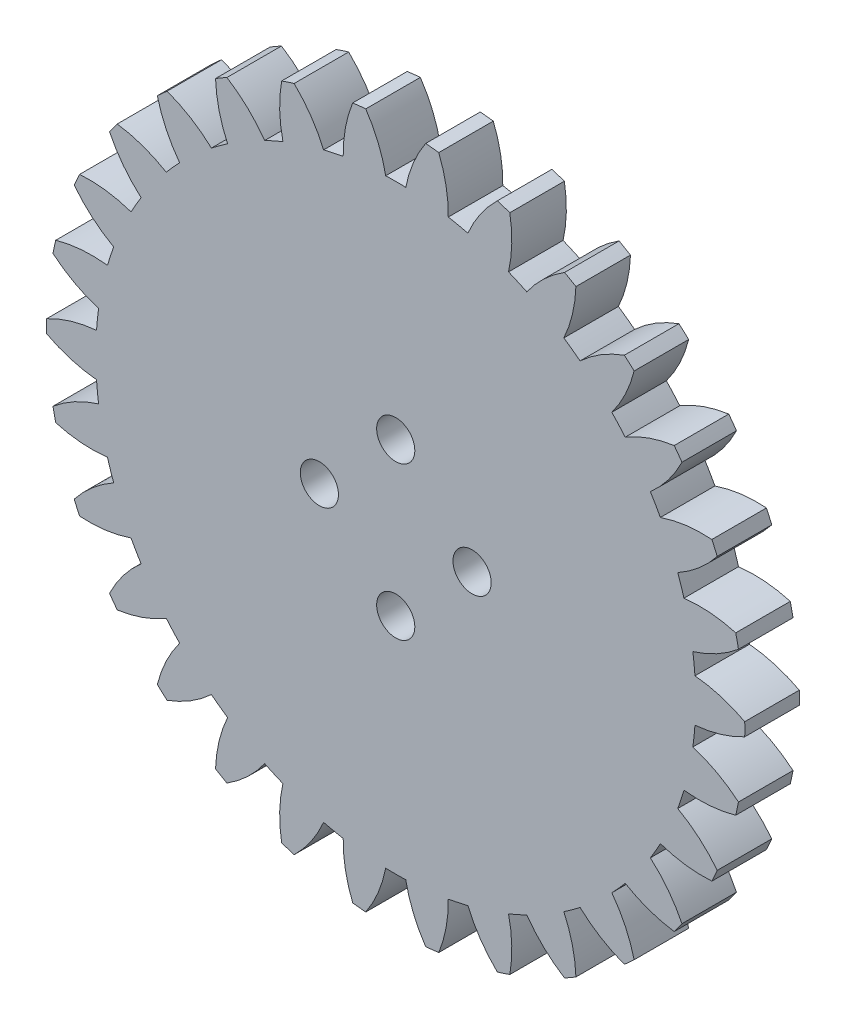
from build123d import *

# Parameters (mm, degrees)
EXTRUDE_1_DEPTH     = 5
SKETCH_2_R          = 1.75
CUT_EXTRUDE_1_DEPTH = 10


with BuildPart() as part:
    # 草图1 → 凸台-拉伸1 (new body)
    with BuildSketch(Plane.XY):
        with BuildLine():
            ThreePointArc((-31.994334603, -0.602124009), (-29.77973059, -1.509475958), (-27.429110937, -1.959304527))
            ThreePointArc((-27.429110937, -1.959304527), (-27.348357601, -2.874428211), (-27.23708137, -3.786343811))
            ThreePointArc((-27.23708137, -3.786343811), (-29.442809726, -4.715063852), (-31.42037025, -6.063030049))
            ThreePointArc((-31.42037025, -6.063030049), (-31.300723223, -6.653174106), (-31.169993008, -7.240962359))
            ThreePointArc((-31.169993008, -7.240962359), (-28.815134328, -7.668044426), (-26.422356736, -7.619321854))
            ThreePointArc((-26.422356736, -7.619321854), (-26.153103142, -8.497658328), (-25.854660649, -9.366510754))
            ThreePointArc((-25.854660649, -9.366510754), (-27.819096794, -10.733532747), (-29.473184945, -12.4632006))
            ThreePointArc((-29.473184945, -12.4632006), (-29.233454645, -13.015572578), (-28.983373149, -13.563335907))
            ThreePointArc((-28.983373149, -13.563335907), (-26.591178426, -13.491482557), (-24.260818757, -12.946338255))
            ThreePointArc((-24.260818757, -12.946338255), (-23.814832579, -13.7495), (-23.342267194, -14.537316233))
            ThreePointArc((-23.342267194, -14.537316233), (-24.979555842, -16.282894755), (-26.23788003, -18.31866948))
            ThreePointArc((-26.23788003, -18.31866948), (-25.88854382, -18.809128073), (-25.530040805, -19.292926592))
            ThreePointArc((-25.530040805, -19.292926592), (-23.205060428, -18.725278161), (-21.038966583, -17.707537551))
            ThreePointArc((-21.038966583, -17.707537551), (-20.435739556, -18.400422544), (-19.809704653, -19.072771234))
            ThreePointArc((-19.809704653, -19.072771234), (-21.048288434, -21.120616129), (-21.855853854, -23.373524601))
            ThreePointArc((-21.855853854, -23.373524601), (-21.412179403, -23.780634415), (-20.960923171, -24.179323808))
            ThreePointArc((-20.960923171, -24.179323808), (-18.804769939, -23.140689255), (-16.897610612, -21.694832486))
            ThreePointArc((-16.897610612, -21.694832486), (-16.163506653, -22.247158328), (-15.411362962, -22.774654611))
            ThreePointArc((-15.411362962, -22.774654611), (-16.197109821, -25.035265229), (-16.518621989, -27.406844539))
            ThreePointArc((-16.518621989, -27.406844539), (-16, -27.712812921), (-15.475712613, -28.008968548))
            ThreePointArc((-15.475712613, -28.008968548), (-13.582620769, -26.544741188), (-12.017747974, -24.733959138))
            ThreePointArc((-12.017747974, -24.733959138), (-11.184850948, -25.12158654), (-10.339470758, -25.481176297))
            ThreePointArc((-10.339470758, -25.481176297), (-10.638039786, -27.855753107), (-10.459447078, -30.242353857))
            ThreePointArc((-10.459447078, -30.242353857), (-9.88854382, -30.433808521), (-9.314139154, -30.61448696))
            ThreePointArc((-9.314139154, -30.61448696), (-7.766845894, -28.788660555), (-6.612652082, -26.692093088))
            ThreePointArc((-6.612652082, -26.692093088), (-5.717363586, -26.898080873), (-4.815694067, -27.074048306))
            ThreePointArc((-4.815694067, -27.074048306), (-4.614036366, -29.458810907), (-3.94314414, -31.756127193))
            ThreePointArc((-3.94314414, -31.756127193), (-3.344910825, -31.824700652), (-2.745493119, -31.882005388))
            ThreePointArc((-2.745493119, -31.882005388), (-1.611622584, -29.774377312), (-0.918551563, -27.483654488))
            ThreePointArc((-0.918551563, -27.483654488), (0, -27.499), (0.918551563, -27.483654488))
            ThreePointArc((0.918551563, -27.483654488), (1.611622584, -29.774377312), (2.745493119, -31.882005388))
            ThreePointArc((2.745493119, -31.882005388), (3.344910825, -31.824700652), (3.94314414, -31.756127193))
            ThreePointArc((3.94314414, -31.756127193), (4.614036366, -29.458810907), (4.815694067, -27.074048306))
            ThreePointArc((4.815694067, -27.074048306), (5.717363586, -26.898080873), (6.612652082, -26.692093088))
            ThreePointArc((6.612652082, -26.692093088), (7.766845894, -28.788660555), (9.314139154, -30.61448696))
            ThreePointArc((9.314139154, -30.61448696), (9.88854382, -30.433808521), (10.459447078, -30.242353857))
            ThreePointArc((10.459447078, -30.242353857), (10.638039786, -27.855753107), (10.339470758, -25.481176297))
            ThreePointArc((10.339470758, -25.481176297), (11.184850948, -25.12158654), (12.017747974, -24.733959138))
            ThreePointArc((12.017747974, -24.733959138), (13.582620769, -26.544741188), (15.475712613, -28.008968548))
            ThreePointArc((15.475712613, -28.008968548), (16, -27.712812921), (16.518621989, -27.406844539))
            ThreePointArc((16.518621989, -27.406844539), (16.197109821, -25.035265229), (15.411362962, -22.774654611))
            ThreePointArc((15.411362962, -22.774654611), (16.163506653, -22.247158328), (16.897610612, -21.694832486))
            ThreePointArc((16.897610612, -21.694832486), (18.804769939, -23.140689255), (20.960923171, -24.179323808))
            ThreePointArc((20.960923171, -24.179323808), (21.412179403, -23.780634415), (21.855853854, -23.373524601))
            ThreePointArc((21.855853854, -23.373524601), (21.048288434, -21.120616129), (19.809704653, -19.072771234))
            ThreePointArc((19.809704653, -19.072771234), (20.435739556, -18.400422544), (21.038966583, -17.707537551))
            ThreePointArc((21.038966583, -17.707537551), (23.205060428, -18.725278161), (25.530040805, -19.292926592))
            ThreePointArc((25.530040805, -19.292926592), (25.88854382, -18.809128073), (26.23788003, -18.31866948))
            ThreePointArc((26.23788003, -18.31866948), (24.979555842, -16.282894755), (23.342267194, -14.537316233))
            ThreePointArc((23.342267194, -14.537316233), (23.814832579, -13.7495), (24.260818757, -12.946338255))
            ThreePointArc((24.260818757, -12.946338255), (26.591178426, -13.491482557), (28.983373149, -13.563335907))
            ThreePointArc((28.983373149, -13.563335907), (29.233454645, -13.015572578), (29.473184945, -12.4632006))
            ThreePointArc((29.473184945, -12.4632006), (27.819096794, -10.733532747), (25.854660649, -9.366510754))
            ThreePointArc((25.854660649, -9.366510754), (26.153103142, -8.497658328), (26.422356736, -7.619321854))
            ThreePointArc((26.422356736, -7.619321854), (28.815134328, -7.668044426), (31.169993008, -7.240962359))
            ThreePointArc((31.169993008, -7.240962359), (31.300723223, -6.653174106), (31.42037025, -6.063030049))
            ThreePointArc((31.42037025, -6.063030049), (29.442809726, -4.715063852), (27.23708137, -3.786343811))
            ThreePointArc((27.23708137, -3.786343811), (27.348357601, -2.874428211), (27.429110937, -1.959304527))
            ThreePointArc((27.429110937, -1.959304527), (29.77973059, -1.509475958), (31.994334603, -0.602124009))
            ThreePointArc((31.994334603, -0.602124009), (32, 0), (31.994334603, 0.602124009))
            ThreePointArc((31.994334603, 0.602124009), (29.77973059, 1.509475958), (27.429110937, 1.959304527))
            ThreePointArc((27.429110937, 1.959304527), (27.348357601, 2.874428211), (27.23708137, 3.786343811))
            ThreePointArc((27.23708137, 3.786343811), (29.442809726, 4.715063852), (31.42037025, 6.063030049))
            ThreePointArc((31.42037025, 6.063030049), (31.300723223, 6.653174106), (31.169993008, 7.240962359))
            ThreePointArc((31.169993008, 7.240962359), (28.815134328, 7.668044426), (26.422356736, 7.619321854))
            ThreePointArc((26.422356736, 7.619321854), (26.153103142, 8.497658328), (25.854660649, 9.366510754))
            ThreePointArc((25.854660649, 9.366510754), (27.819096794, 10.733532747), (29.473184945, 12.4632006))
            ThreePointArc((29.473184945, 12.4632006), (29.233454645, 13.015572578), (28.983373149, 13.563335907))
            ThreePointArc((28.983373149, 13.563335907), (26.591178426, 13.491482557), (24.260818757, 12.946338255))
            ThreePointArc((24.260818757, 12.946338255), (23.814832579, 13.7495), (23.342267194, 14.537316233))
            ThreePointArc((23.342267194, 14.537316233), (24.979555842, 16.282894755), (26.23788003, 18.31866948))
            ThreePointArc((26.23788003, 18.31866948), (25.88854382, 18.809128073), (25.530040805, 19.292926592))
            ThreePointArc((25.530040805, 19.292926592), (23.205060428, 18.725278161), (21.038966583, 17.707537551))
            ThreePointArc((21.038966583, 17.707537551), (20.435739556, 18.400422544), (19.809704653, 19.072771234))
            ThreePointArc((19.809704653, 19.072771234), (21.048288434, 21.120616129), (21.855853854, 23.373524601))
            ThreePointArc((21.855853854, 23.373524601), (21.412179403, 23.780634415), (20.960923171, 24.179323808))
            ThreePointArc((20.960923171, 24.179323808), (18.804769939, 23.140689255), (16.897610612, 21.694832486))
            ThreePointArc((16.897610612, 21.694832486), (16.163506653, 22.247158328), (15.411362962, 22.774654611))
            ThreePointArc((15.411362962, 22.774654611), (16.197109821, 25.035265229), (16.518621989, 27.406844539))
            ThreePointArc((16.518621989, 27.406844539), (16, 27.712812921), (15.475712613, 28.008968548))
            ThreePointArc((15.475712613, 28.008968548), (13.582620769, 26.544741188), (12.017747974, 24.733959138))
            ThreePointArc((12.017747974, 24.733959138), (11.184850948, 25.12158654), (10.339470758, 25.481176297))
            ThreePointArc((10.339470758, 25.481176297), (10.638039786, 27.855753107), (10.459447078, 30.242353857))
            ThreePointArc((10.459447078, 30.242353857), (9.88854382, 30.433808521), (9.314139154, 30.61448696))
            ThreePointArc((9.314139154, 30.61448696), (7.766845894, 28.788660555), (6.612652082, 26.692093088))
            ThreePointArc((6.612652082, 26.692093088), (5.717363586, 26.898080873), (4.815694067, 27.074048306))
            ThreePointArc((4.815694067, 27.074048306), (4.614036366, 29.458810907), (3.94314414, 31.756127193))
            ThreePointArc((3.94314414, 31.756127193), (3.344910825, 31.824700652), (2.745493119, 31.882005388))
            ThreePointArc((2.745493119, 31.882005388), (1.611622584, 29.774377312), (0.918551563, 27.483654488))
            ThreePointArc((0.918551563, 27.483654488), (0, 27.499), (-0.918551563, 27.483654488))
            ThreePointArc((-0.918551563, 27.483654488), (-1.611622584, 29.774377312), (-2.745493119, 31.882005388))
            ThreePointArc((-2.745493119, 31.882005388), (-3.344910825, 31.824700652), (-3.94314414, 31.756127193))
            ThreePointArc((-3.94314414, 31.756127193), (-4.614036366, 29.458810907), (-4.815694067, 27.074048306))
            ThreePointArc((-4.815694067, 27.074048306), (-5.717363586, 26.898080873), (-6.612652082, 26.692093088))
            ThreePointArc((-6.612652082, 26.692093088), (-7.766845894, 28.788660555), (-9.314139154, 30.61448696))
            ThreePointArc((-9.314139154, 30.61448696), (-9.88854382, 30.433808521), (-10.459447078, 30.242353857))
            ThreePointArc((-10.459447078, 30.242353857), (-10.638039786, 27.855753107), (-10.339470758, 25.481176297))
            ThreePointArc((-10.339470758, 25.481176297), (-11.184850948, 25.12158654), (-12.017747974, 24.733959138))
            ThreePointArc((-12.017747974, 24.733959138), (-13.582620769, 26.544741188), (-15.475712613, 28.008968548))
            ThreePointArc((-15.475712613, 28.008968548), (-16, 27.712812921), (-16.518621989, 27.406844539))
            ThreePointArc((-16.518621989, 27.406844539), (-16.197109821, 25.035265229), (-15.411362962, 22.774654611))
            ThreePointArc((-15.411362962, 22.774654611), (-16.163506653, 22.247158328), (-16.897610612, 21.694832486))
            ThreePointArc((-16.897610612, 21.694832486), (-18.804769939, 23.140689255), (-20.960923171, 24.179323808))
            ThreePointArc((-20.960923171, 24.179323808), (-21.412179403, 23.780634415), (-21.855853854, 23.373524601))
            ThreePointArc((-21.855853854, 23.373524601), (-21.048288434, 21.120616129), (-19.809704653, 19.072771234))
            ThreePointArc((-19.809704653, 19.072771234), (-20.435739556, 18.400422544), (-21.038966583, 17.707537551))
            ThreePointArc((-21.038966583, 17.707537551), (-23.205060428, 18.725278161), (-25.530040805, 19.292926592))
            ThreePointArc((-25.530040805, 19.292926592), (-25.88854382, 18.809128073), (-26.23788003, 18.31866948))
            ThreePointArc((-26.23788003, 18.31866948), (-24.979555842, 16.282894755), (-23.342267194, 14.537316233))
            ThreePointArc((-23.342267194, 14.537316233), (-23.814832579, 13.7495), (-24.260818757, 12.946338255))
            ThreePointArc((-24.260818757, 12.946338255), (-26.591178426, 13.491482557), (-28.983373149, 13.563335907))
            ThreePointArc((-28.983373149, 13.563335907), (-29.233454645, 13.015572578), (-29.473184945, 12.4632006))
            ThreePointArc((-29.473184945, 12.4632006), (-27.819096794, 10.733532747), (-25.854660649, 9.366510754))
            ThreePointArc((-25.854660649, 9.366510754), (-26.153103142, 8.497658328), (-26.422356736, 7.619321854))
            ThreePointArc((-26.422356736, 7.619321854), (-28.815134328, 7.668044426), (-31.169993008, 7.240962359))
            ThreePointArc((-31.169993008, 7.240962359), (-31.300723223, 6.653174106), (-31.42037025, 6.063030049))
            ThreePointArc((-31.42037025, 6.063030049), (-29.442809726, 4.715063852), (-27.23708137, 3.786343811))
            ThreePointArc((-27.23708137, 3.786343811), (-27.348357601, 2.874428211), (-27.429110937, 1.959304527))
            ThreePointArc((-27.429110937, 1.959304527), (-29.77973059, 1.509475958), (-31.994334603, 0.602124009))
            ThreePointArc((-31.994334603, 0.602124009), (-32, 0), (-31.994334603, -0.602124009))
        make_face()
    extrude(amount=EXTRUDE_1_DEPTH)

    # 草图2 → 切除-拉伸1 (cut)
    with BuildSketch(Plane.XY.offset(5)):
        with Locations((0, 7)):
            Circle(SKETCH_2_R)
        with Locations((7, 0)):
            Circle(SKETCH_2_R)
        with Locations((0, -7)):
            Circle(SKETCH_2_R)
        with Locations((-7, 0)):
            Circle(SKETCH_2_R)
    extrude(amount=-CUT_EXTRUDE_1_DEPTH, mode=Mode.SUBTRACT)


solid = part.part
